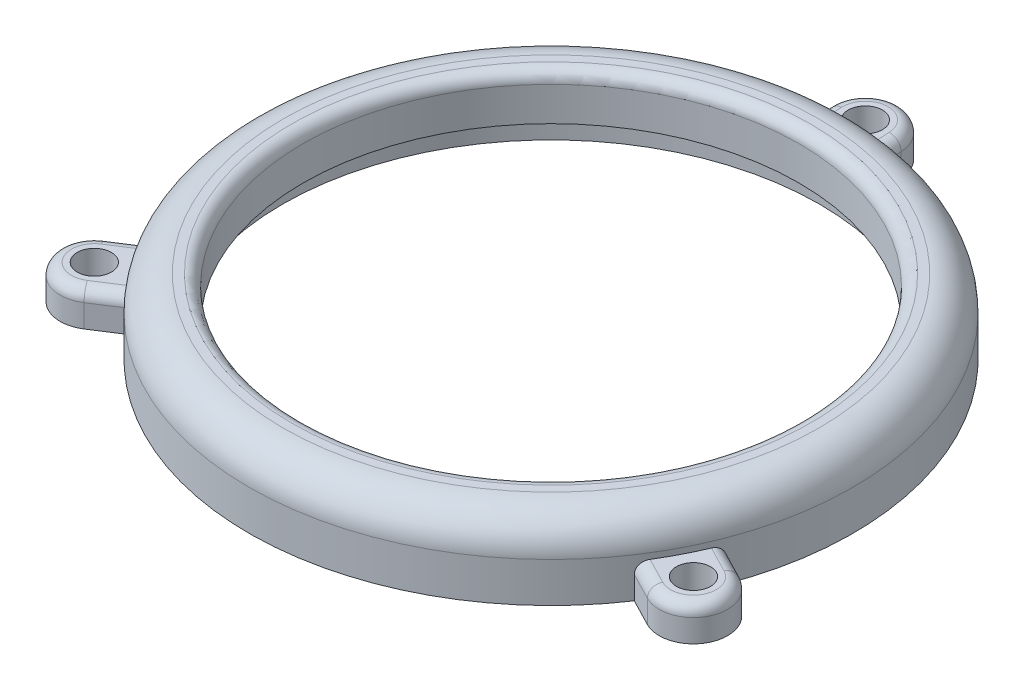
from build123d import *

# Parameters (mm, degrees)
SKETCH1_R           = 26.5
SKETCH1_R_2         = 21.75
BOSS_EXTRUDE1_DEPTH = 6.5
FILLET1_R           = 3
SKETCH2_R           = 23.55
SKETCH2_R_2         = 21.75
CUT_EXTRUDE1_DEPTH  = 2.51
SKETCH3_R           = 1.5
BOSS_EXTRUDE2_DEPTH = 3
CIRPATTERN1_COUNT   = 3
FILLET2_R           = 1
FILLET4_R           = 1


with BuildPart() as part:
    # Sketch1 → Boss-Extrude1 (new body)
    with BuildSketch(Plane(origin=(0, 0, 0), x_dir=(1, 0, 0), z_dir=(0, 1, 0))):
        Circle(SKETCH1_R)
        Circle(SKETCH1_R_2, mode=Mode.SUBTRACT)
    extrude(amount=BOSS_EXTRUDE1_DEPTH)

    # Fillet1
    fillet1_edges = [part.edges().sort_by_distance(p)[0] for p in [
        (-26.5, 6.5, 0),
    ]]
    fillet(fillet1_edges, radius=FILLET1_R)

    # Sketch2 → Cut-Extrude1 (cut)
    with BuildSketch(Plane.XZ):
        Circle(SKETCH2_R)
        Circle(SKETCH2_R_2, mode=Mode.SUBTRACT)
    extrude(amount=-CUT_EXTRUDE1_DEPTH, mode=Mode.SUBTRACT)

    # Sketch3 → Boss-Extrude2 (add)
    with BuildSketch(Plane.XZ):
        with BuildLine():
            Line((-20.523964569, 16.763558046), (-23.769018949, 11.716814337))
            Line((-23.769018949, 11.716814337), (-26.015121786, 13.161057649))
            ThreePointArc((-26.015121786, 13.161057649), (-26.915966451, 17.306956694), (-22.770067406, 18.207801359))
            Line((-22.770067406, 18.207801359), (-20.523964569, 16.763558046))
        make_face()
        with Locations((-24.392594596, 15.684429504)):
            Circle(SKETCH3_R, mode=Mode.SUBTRACT)
    boss_extrude2 = extrude(amount=-BOSS_EXTRUDE2_DEPTH)

    # CirPattern1: Boss-Extrude2 ×3 about axis
    cirpattern1_axis = Axis((0, 0, 0), (0, 1, 0))
    for i in range(1, CIRPATTERN1_COUNT):
        add(boss_extrude2.rotate(cirpattern1_axis, i * 360 / CIRPATTERN1_COUNT))

    # Fillet2
    fillet2_edges = [part.edges().sort_by_distance(p)[0] for p in [
        (-21.75, 6.5, 0),
    ]]
    fillet(fillet2_edges, radius=FILLET2_R)

    # Fillet4
    fillet4_edges = [part.edges().sort_by_distance(p)[0] for p in [
        (-21.647015988, 3, 17.485679702),
        (-24.892070368, 3, 12.438935993),
        (-26.915966451, 3, 17.306956694),
        (-4.319534831, 3, -27.489705613),
        (1.673600618, 3, -27.776633288),
        (-1.530280933, 3, -31.963389061),
        (25.966550819, 3, 10.00402591),
        (23.21846975, 3, 15.337697295),
        (28.446247385, 3, 14.656432367),
    ]]
    fillet(fillet4_edges, radius=FILLET4_R)


solid = part.part
